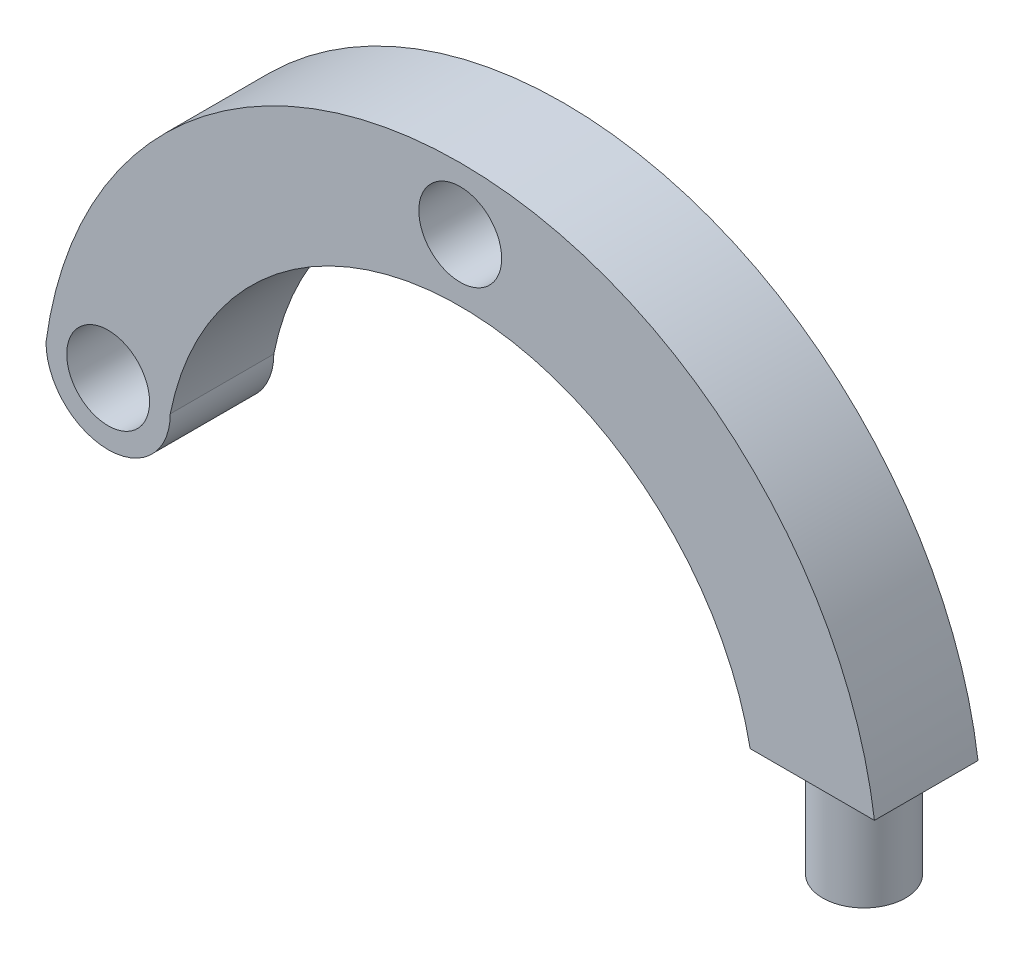
from build123d import *

# Parameters (mm, degrees)
CROQUIS1_R              = 20
SALIENTE_EXTRUIR1_DEPTH = 50
CROQUIS2_R              = 20
SALIENTE_EXTRUIR2_DEPTH = 50


with BuildPart() as part:
    # Croquis1 → Saliente-Extruir1 (new body)
    with BuildSketch(Plane.XY):
        with BuildLine():
            Line((140, -145), (200, -145))
            ThreePointArc((200, -145), (0, 30), (-200, -145))
            ThreePointArc((-200, -145), (-170, -175), (-140, -145))
            ThreePointArc((-140, -145), (0, -30), (140, -145))
        make_face()
        Circle(CROQUIS1_R, mode=Mode.SUBTRACT)
        with Locations((-170, -145)):
            Circle(CROQUIS1_R, mode=Mode.SUBTRACT)
    extrude(amount=SALIENTE_EXTRUIR1_DEPTH)

    # Croquis2 → Saliente-Extruir2 (add)
    with BuildSketch(Plane.XZ.offset(145)):
        with Locations((170, 25)):
            Circle(CROQUIS2_R)
    extrude(amount=SALIENTE_EXTRUIR2_DEPTH)


solid = part.part
